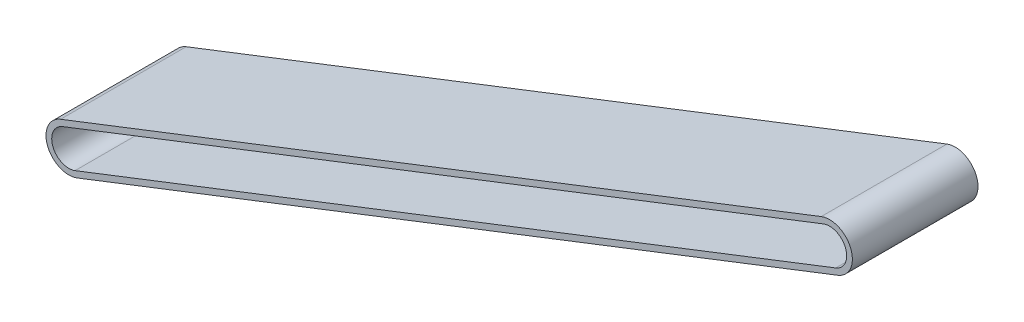
from build123d import *

# Parameters (mm, degrees)
BOSS_EXTRUDE1_DEPTH = 139.7
CUT_EXTRUDE1_DEPTH  = 1903.021697166


with BuildPart() as part:
    # Sketch2 → Boss-Extrude1 (new, symmetric)
    with BuildSketch(Plane.XY):
        with BuildLine():
            Line((-18.425433745, 47.340715999), (1673.352830516, 705.796078626))
            ThreePointArc((1673.352830516, 705.796078626), (1739.11898026, 676.880796373), (1710.203698007, 611.114646628))
            Line((1710.203698007, 611.114646628), (18.425433745, -47.340715999))
            ThreePointArc((18.425433745, -47.340715999), (-47.340715999, -18.425433745), (-18.425433745, 47.340715999))
        make_face()
    extrude(amount=BOSS_EXTRUDE1_DEPTH, both=True)

    # Sketch7 → Cut-Extrude1 (cut, through all)
    with BuildSketch(Plane.XY.offset(139.7)):
        with BuildLine():
            Line((13.819075309, -35.505536999), (1705.59733957, 622.949825628))
            ThreePointArc((1705.59733957, 622.949825628), (1727.283801261, 672.274437937), (1677.959188952, 693.960899627))
            Line((1677.959188952, 693.960899627), (-13.819075309, 35.505536999))
            ThreePointArc((-13.819075309, 35.505536999), (-35.505536999, -13.819075309), (13.819075309, -35.505536999))
        make_face()
    extrude(amount=-CUT_EXTRUDE1_DEPTH, mode=Mode.SUBTRACT)


solid = part.part
